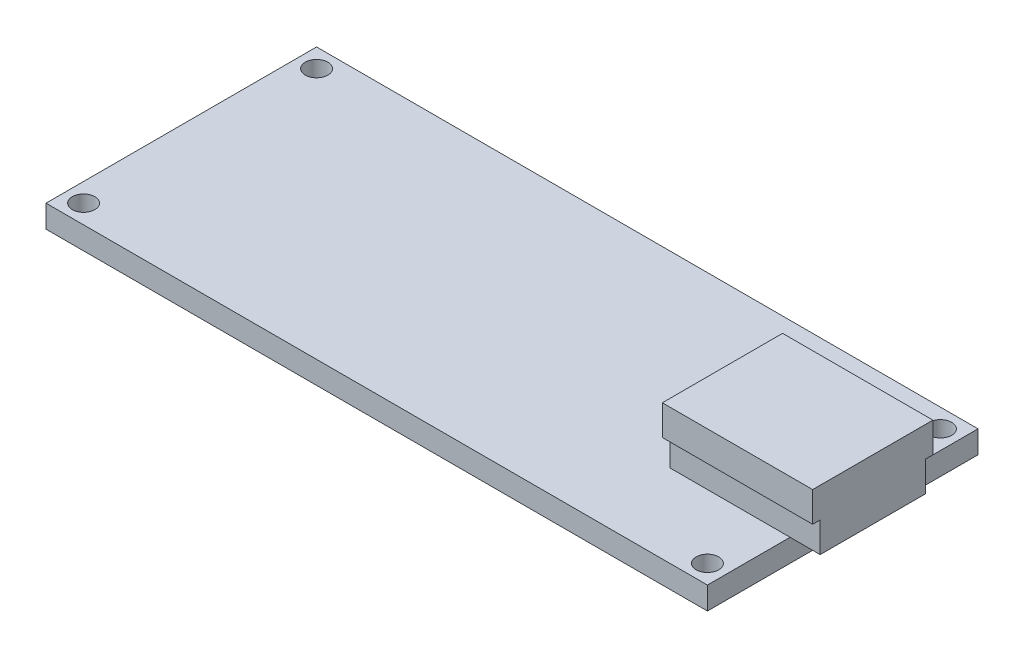
from build123d import *

# Parameters (mm, degrees)
SCHIZZO1_W                   = 44
SCHIZZO1_H                   = 18
ESTRUSIONE_ESTRUSIONE1_DEPTH = 1.5
SCHIZZO2_R                   = 0.75
TAGLIO_ESTRUSIONE1_DEPTH     = 1.5
SCHIZZO4_W                   = 10
SCHIZZO4_H                   = 7
ESTRUSIONE_ESTRUSIONE2_DEPTH = 2
SCHIZZO5_W                   = 10
SCHIZZO5_H                   = 8
ESTRUSIONE_ESTRUSIONE3_DEPTH = 2


with BuildPart() as part:
    # Schizzo1 → Estrusione-Estrusione1 (new body)
    with BuildSketch(Plane(origin=(0, 0, 0), x_dir=(1, 0, 0), z_dir=(0, 1, 0))):
        Rectangle(SCHIZZO1_W, SCHIZZO1_H)
    extrude(amount=ESTRUSIONE_ESTRUSIONE1_DEPTH)

    # Schizzo2 → Taglio-Estrusione1 (cut)
    with BuildSketch(Plane(origin=(0, 1.5, 0), x_dir=(1, 0, 0), z_dir=(0, 1, 0))):
        with Locations((-20.75, 7.75)):
            Circle(SCHIZZO2_R)
        with Locations((20.75, 7.75)):
            Circle(SCHIZZO2_R)
        with Locations((20.75, -7.75)):
            Circle(SCHIZZO2_R)
        with Locations((-20.75, -7.75)):
            Circle(SCHIZZO2_R)
    extrude(amount=-TAGLIO_ESTRUSIONE1_DEPTH, mode=Mode.SUBTRACT)

    # Schizzo4 → Estrusione-Estrusione2 (add)
    with BuildSketch(Plane(origin=(0, 1.5, 0), x_dir=(1, 0, 0), z_dir=(0, 1, 0))):
        with Locations((19, 0)):
            Rectangle(SCHIZZO4_W, SCHIZZO4_H)
    extrude(amount=ESTRUSIONE_ESTRUSIONE2_DEPTH)

    # Schizzo5 → Estrusione-Estrusione3 (add)
    with BuildSketch(Plane(origin=(0, 3.5, 0), x_dir=(1, 0, 0), z_dir=(0, 1, 0))):
        with Locations((19, 0)):
            Rectangle(SCHIZZO5_W, SCHIZZO5_H)
    extrude(amount=ESTRUSIONE_ESTRUSIONE3_DEPTH)


solid = part.part
